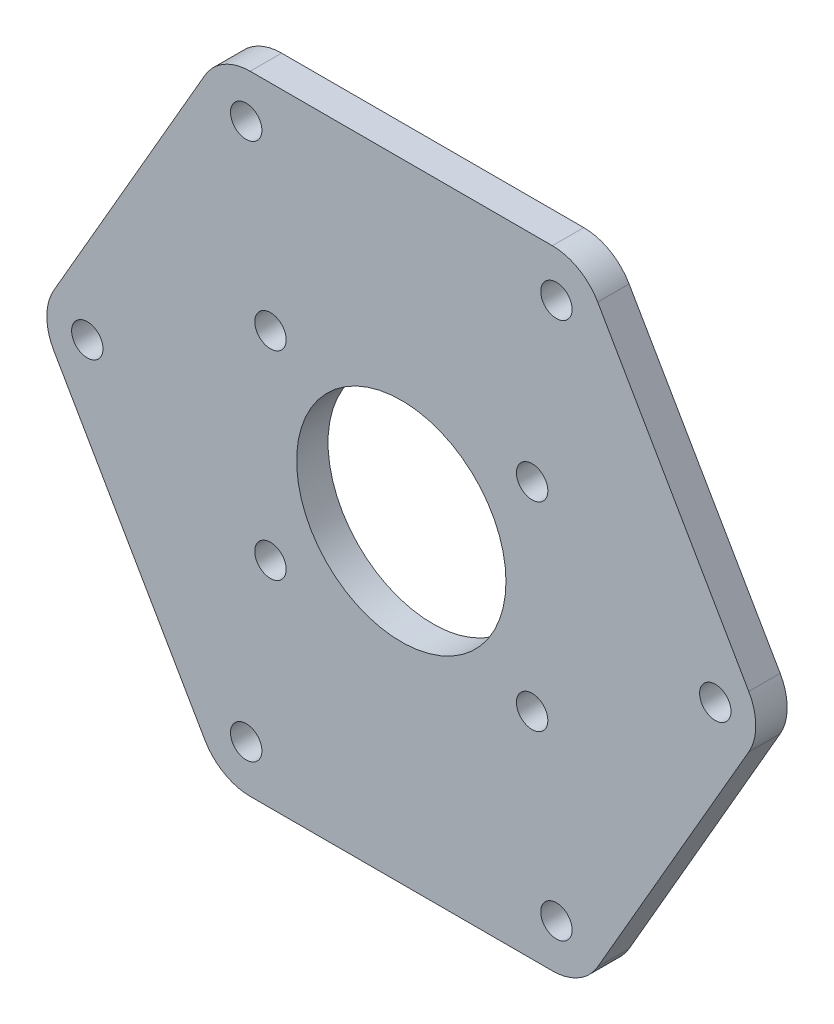
from build123d import *

# Parameters (mm, degrees)
EXTRUDE_1_DEPTH     = 3
SKETCH_2_R          = 10
SKETCH_2_R_2        = 1.5
CUT_EXTRUDE_1_DEPTH = 3
SKETCH_3_R          = 1.5
CUT_EXTRUDE_2_DEPTH = 3
FILLET_1_R          = 5


with BuildPart() as part:
    # 草图1 → 凸台-拉伸1 (new body)
    with BuildSketch(Plane.XY):
        Polygon((34.641016151, 0), (17.320508076, 30), (-17.320508076, 30), (-34.641016151, 0), (-17.320508076, -30), (17.320508076, -30), align=None)
    extrude(amount=EXTRUDE_1_DEPTH)

    # 草图2 → 切除-拉伸1 (cut)
    with BuildSketch(Plane.XY.offset(3)):
        Circle(SKETCH_2_R)
        with Locations((-12.5, 9.5)):
            Circle(SKETCH_2_R_2)
        with Locations((12.5, 9.5)):
            Circle(SKETCH_2_R_2)
        with Locations((-12.5, -9.5)):
            Circle(SKETCH_2_R_2)
        with Locations((12.5, -9.5)):
            Circle(SKETCH_2_R_2)
    extrude(amount=-CUT_EXTRUDE_1_DEPTH, mode=Mode.SUBTRACT)

    # 草图3 → 切除-拉伸2 (cut)
    with BuildSketch(Plane.XY.offset(3)):
        with Locations((-30, 0)):
            Circle(SKETCH_3_R)
        with Locations((30, 0)):
            Circle(SKETCH_3_R)
        with Locations((-14.820508076, -25.669872981)):
            Circle(SKETCH_3_R)
        with Locations((14.820508076, -25.669872981)):
            Circle(SKETCH_3_R)
        with Locations((-14.820508076, 25.669872981)):
            Circle(SKETCH_3_R)
        with Locations((14.820508076, 25.669872981)):
            Circle(SKETCH_3_R)
    extrude(amount=-CUT_EXTRUDE_2_DEPTH, mode=Mode.SUBTRACT)

    # 圆角1
    fillet_1_edges = [part.edges().sort_by_distance(p)[0] for p in [
        (17.320508076, -30, 1.5),
        (-17.320508076, -30, 1.5),
        (-34.641016151, 0, 1.5),
        (-17.320508076, 30, 1.5),
        (17.320508076, 30, 1.5),
        (34.641016151, 0, 1.5),
    ]]
    fillet(fillet_1_edges, radius=FILLET_1_R)


solid = part.part
